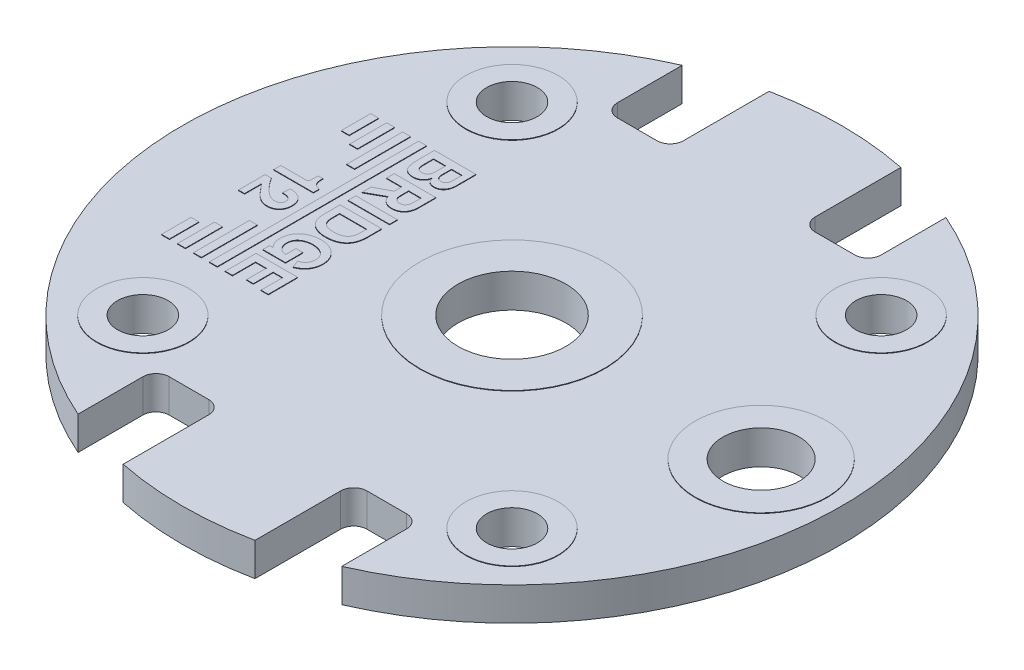
from build123d import *

# Parameters (mm, degrees)
BOSS_EXTRUDE1_DEPTH   = 0.8
SKETCH12_R            = 2.6
CUT_EXTRUDE2_DEPTH    = 23.507582056
F_2_CLEARANCE_HOLE1_D = 2.4384
SKETCH6_R             = 1.8415
CUT_EXTRUDE1_DEPTH    = 23.507582056
SKETCH8_R             = 2.2225
SKETCH8_R_2           = 1.2192
SKETCH8_R_3           = 3.175
SKETCH8_R_4           = 1.8415
SKETCH8_R_5           = 4.445
SKETCH8_R_6           = 2.6
BOSS_EXTRUDE6_DEPTH   = 0.0254
SKETCH10_W            = 2.000200165
SKETCH10_H            = 0.376434594
SKETCH10_W_2          = 0.384040879
SKETCH10_H_2          = 2.6975922
SKETCH10_W_3          = 0.384179562
SKETCH10_H_3          = 1.785047947
SKETCH10_W_4          = 0.384111999
SKETCH10_H_4          = 1.42007434
SKETCH10_H_5          = 2.69760998
SKETCH10_H_6          = 1.785033723
SKETCH10_H_7          = 1.420021
SKETCH10_W_5          = 0.384040878
SKETCH10_H_8          = 10.078361606
BOSS_EXTRUDE7_DEPTH   = 0.0254


with BuildPart() as part:
    # Sketch1 → Boss-Extrude1 (new, symmetric)
    with BuildSketch(Plane(origin=(0, 0, 0), x_dir=(1, 0, 0), z_dir=(0, 1, 0))):
        with BuildLine():
            Line((-6.35, 14.549677831), (-6.35, 11.43))
            ThreePointArc((-6.35, 11.43), (-6.164012806, 10.980987194), (-5.715, 10.795))
            Line((-5.715, 10.795), (-3.81, 10.795))
            ThreePointArc((-3.81, 10.795), (-3.360987194, 10.980987194), (-3.175, 11.43))
            Line((-3.175, 11.43), (-3.175, 15.554259867))
            ThreePointArc((-3.175, 15.554259867), (0, 15.875), (3.175, 15.554259867))
            Line((3.175, 15.554259867), (3.175, 11.43))
            ThreePointArc((3.175, 11.43), (3.360987194, 10.980987194), (3.81, 10.795))
            Line((3.81, 10.795), (5.715, 10.795))
            ThreePointArc((5.715, 10.795), (6.164012806, 10.980987194), (6.35, 11.43))
            Line((6.35, 11.43), (6.35, 14.549677831))
            ThreePointArc((6.35, 14.549677831), (15.875, 0), (6.35, -14.549677831))
            Line((6.35, -14.549677831), (6.35, -11.43))
            ThreePointArc((6.35, -11.43), (6.164012806, -10.980987194), (5.715, -10.795))
            Line((5.715, -10.795), (3.81, -10.795))
            ThreePointArc((3.81, -10.795), (3.360987194, -10.980987194), (3.175, -11.43))
            Line((3.175, -11.43), (3.175, -15.554259867))
            ThreePointArc((3.175, -15.554259867), (0, -15.875), (-3.175, -15.554259867))
            Line((-3.175, -15.554259867), (-3.175, -11.43))
            ThreePointArc((-3.175, -11.43), (-3.360987194, -10.980987194), (-3.81, -10.795))
            Line((-3.81, -10.795), (-5.715, -10.795))
            ThreePointArc((-5.715, -10.795), (-6.164012806, -10.980987194), (-6.35, -11.43))
            Line((-6.35, -11.43), (-6.35, -14.549677831))
            ThreePointArc((-6.35, -14.549677831), (-15.875, 0), (-6.35, 14.549677831))
        make_face()
    extrude(amount=BOSS_EXTRUDE1_DEPTH, both=True)

    # Sketch12 → Cut-Extrude2 (cut, through all)
    with BuildSketch(Plane(origin=(0, 0.8, 0), x_dir=(1, 0, 0), z_dir=(0, 1, 0))):
        with Locations(Location((0, 0, 0), (0, 0, 270))):
            Circle(SKETCH12_R)
    extrude(amount=-CUT_EXTRUDE2_DEPTH, mode=Mode.SUBTRACT)

    # #2 Clearance Hole1 (through all)
    with Locations(Plane(origin=(0, 0.8, 0), x_dir=(1, 0, 0), z_dir=(0, 1, 0))):
        with Locations((-8.89, 8.89), (8.89, -8.89), (-8.89, -8.89), (8.89, 8.89)):
            Hole(F_2_CLEARANCE_HOLE1_D / 2)

    # Sketch6 → Cut-Extrude1 (cut, through all)
    with BuildSketch(Plane(origin=(0, 0.8, 0), x_dir=(1, 0, 0), z_dir=(0, 1, 0))):
        with Locations(Location((12, 0, 0), (0, 0, 270))):
            Circle(SKETCH6_R)
    extrude(amount=-CUT_EXTRUDE1_DEPTH, mode=Mode.SUBTRACT)

    # Sketch8 → Boss-Extrude6 (add)
    with BuildSketch(Plane(origin=(0, 0.8, 0), x_dir=(1, 0, 0), z_dir=(0, 1, 0))):
        with Locations(Location((-8.89, 8.89, 0), (0, 0, 270))):
            Circle(SKETCH8_R)
        with Locations(Location((-8.89, 8.89, 0), (0, 0, 270))):
            Circle(SKETCH8_R_2, mode=Mode.SUBTRACT)
        with Locations(Location((8.89, 8.89, 0), (0, 0, 270))):
            Circle(SKETCH8_R)
        with Locations(Location((8.89, 8.89, 0), (0, 0, 270))):
            Circle(SKETCH8_R_2, mode=Mode.SUBTRACT)
        with Locations(Location((12, 0, 0), (0, 0, 270))):
            Circle(SKETCH8_R_3)
        with Locations(Location((12, 0, 0), (0, 0, 270))):
            Circle(SKETCH8_R_4, mode=Mode.SUBTRACT)
        with Locations(Location((0, 0, 0), (0, 0, 270))):
            Circle(SKETCH8_R_5)
        with Locations(Location((0, 0, 0), (0, 0, 270))):
            Circle(SKETCH8_R_6, mode=Mode.SUBTRACT)
        with Locations(Location((8.89, -8.89, 0), (0, 0, 270))):
            Circle(SKETCH8_R)
        with Locations(Location((8.89, -8.89, 0), (0, 0, 270))):
            Circle(SKETCH8_R_2, mode=Mode.SUBTRACT)
        with Locations(Location((-8.89, -8.89, 0), (0, 0, 270))):
            Circle(SKETCH8_R)
        with Locations(Location((-8.89, -8.89, 0), (0, 0, 270))):
            Circle(SKETCH8_R_2, mode=Mode.SUBTRACT)
    extrude(amount=BOSS_EXTRUDE6_DEPTH)

    # Sketch10 → Boss-Extrude7 (add)
    with BuildSketch(Plane(origin=(0, 0.8, 0), x_dir=(1, 0, 0), z_dir=(0, 1, 0))):
        with BuildLine():
            Line((-6.741945628, 5.008278357), (-6.741945628, 4.067190093))
            add(Edge.make_bspline(
                [(-6.741945628, 4.067190093), (-6.741945628, 3.738501909), (-6.907697896, 3.474444024), (-7.239195319, 3.474444024)],
                knots=[1, 1, 1, 1, 2, 2, 2, 2], degree=3))
            add(Edge.make_bspline(
                [(-7.239195319, 3.474444024), (-7.458323146, 3.474444024), (-7.60158727, 3.595237784), (-7.643725869, 3.814344275)],
                knots=[2, 2, 2, 2, 3, 3, 3, 3], degree=3))
            Line((-7.643725869, 3.814344275), (-7.649351461, 3.814344275))
            add(Edge.make_bspline(
                [(-7.649351461, 3.814344275), (-7.677429636, 3.53904943), (-7.904992294, 3.384534122), (-8.143770576, 3.384534122)],
                knots=[4, 4, 4, 4, 5, 5, 5, 5], degree=3))
            add(Edge.make_bspline(
                [(-8.143770576, 3.384534122), (-8.643833064, 3.384534122), (-8.742145793, 3.741314705), (-8.742145793, 4.157078658)],
                knots=[5, 5, 5, 5, 6, 6, 6, 6], degree=3))
            Line((-8.742145793, 4.157078658), (-8.742145793, 5.008278357))
            Line((-8.742145793, 5.008278357), (-6.741945628, 5.008278357))
        make_face()
        with BuildLine():
            Line((-8.410644814, 4.631843762), (-8.410644814, 4.143032459))
            add(Edge.make_bspline(
                [(-8.410644814, 4.143032459), (-8.410644814, 3.91548758), (-8.340428039, 3.777831268), (-8.132536816, 3.777831268)],
                knots=[1, 1, 1, 1, 2, 2, 2, 2], degree=3))
            add(Edge.make_bspline(
                [(-8.132536816, 3.777831268), (-7.90778731, 3.777831268), (-7.826319352, 3.918300376), (-7.826319352, 4.145845255)],
                knots=[2, 2, 2, 2, 3, 3, 3, 3], degree=3))
            Line((-7.826319352, 4.145845255), (-7.826319352, 4.631843762))
            Line((-7.826319352, 4.631843762), (-8.410644814, 4.631843762))
        make_face(mode=Mode.SUBTRACT)
        with BuildLine():
            Line((-7.545398916, 4.631843762), (-7.545398916, 4.185174614))
            add(Edge.make_bspline(
                [(-7.545398916, 4.185174614), (-7.545398916, 4.019422346), (-7.480789953, 3.867737614), (-7.289758082, 3.867737614)],
                knots=[1, 1, 1, 1, 2, 2, 2, 2], degree=3))
            add(Edge.make_bspline(
                [(-7.289758082, 3.867737614), (-7.13805557, 3.867737614), (-7.039728616, 3.966050343), (-7.039728616, 4.185174614)],
                knots=[2, 2, 2, 2, 3, 3, 3, 3], degree=3))
            Line((-7.039728616, 4.185174614), (-7.039728616, 4.631843762))
            Line((-7.039728616, 4.631843762), (-7.545398916, 4.631843762))
        make_face(mode=Mode.SUBTRACT)
        with BuildLine():
            Line((-6.741945628, 3.07274405), (-6.741945628, 2.238403347))
            add(Edge.make_bspline(
                [(-6.741945628, 2.238403347), (-6.741945628, 1.814201005), (-6.994791445, 1.564185764), (-7.345946437, 1.564185764)],
                knots=[1, 1, 1, 1, 2, 2, 2, 2], degree=3))
            add(Edge.make_bspline(
                [(-7.345946437, 1.564185764), (-7.795428016, 1.564185764), (-7.899366703, 1.864760212), (-7.93587971, 1.960277926)],
                knots=[2, 2, 2, 2, 3, 3, 3, 3], degree=3))
            Line((-7.93587971, 1.960277926), (-8.742145793, 1.513605221))
            Line((-8.742145793, 1.513605221), (-8.742145793, 1.949044522))
            Line((-8.742145793, 1.949044522), (-8.006114264, 2.3367303))
            Line((-8.006114264, 2.3367303), (-8.006114264, 2.696305899))
            Line((-8.006114264, 2.696305899), (-8.742145793, 2.696305899))
            Line((-8.742145793, 2.696305899), (-8.742145793, 3.07274405))
            Line((-8.742145793, 3.07274405), (-6.741945628, 3.07274405))
        make_face()
        with BuildLine():
            Line((-7.67463462, 2.696305899), (-7.67463462, 2.286149758))
            add(Edge.make_bspline(
                [(-7.67463462, 2.286149758), (-7.67463462, 2.095139222), (-7.562257911, 1.95748291), (-7.374038836, 1.95748291)],
                knots=[1, 1, 1, 1, 2, 2, 2, 2], degree=3))
            add(Edge.make_bspline(
                [(-7.374038836, 1.95748291), (-7.191431129, 1.95748291), (-7.073446607, 2.081089467), (-7.073446607, 2.342338112)],
                knots=[2, 2, 2, 2, 3, 3, 3, 3], degree=3))
            Line((-7.073446607, 2.342338112), (-7.073446607, 2.696305899))
            Line((-7.073446607, 2.696305899), (-7.67463462, 2.696305899))
        make_face(mode=Mode.SUBTRACT)
        with Locations((-7.742045711, 1.033269643)):
            Rectangle(SKETCH10_W, SKETCH10_H)
        with BuildLine():
            Line((-6.741945628, 0.46578362), (-6.741945628, -0.236508583))
            add(Edge.make_bspline(
                [(-6.741945628, -0.236508583), (-6.741945628, -0.927599385), (-7.168960765, -1.219757094), (-7.742056379, -1.219757094)],
                knots=[1, 1, 1, 1, 2, 2, 2, 2], degree=3))
            add(Edge.make_bspline(
                [(-7.742056379, -1.219757094), (-8.393803598, -1.219757094), (-8.742145793, -0.902319782), (-8.742145793, -0.306760917)],
                knots=[2, 2, 2, 2, 3, 3, 3, 3], degree=3))
            Line((-8.742145793, -0.306760917), (-8.742145793, 0.46578362))
            Line((-8.742145793, 0.46578362), (-6.741945628, 0.46578362))
        make_face()
        with BuildLine():
            Line((-8.393803598, 0.089366805), (-8.393803598, -0.253385358))
            add(Edge.make_bspline(
                [(-8.393803598, -0.253385358), (-8.393803598, -0.624194361), (-8.258960082, -0.826477416), (-7.742056379, -0.826477416)],
                knots=[1, 1, 1, 1, 2, 2, 2, 2], degree=3))
            add(Edge.make_bspline(
                [(-7.742056379, -0.826477416), (-7.348758856, -0.826477416), (-7.090305603, -0.655103112), (-7.090305603, -0.244946971)],
                knots=[2, 2, 2, 2, 3, 3, 3, 3], degree=3))
            Line((-7.090305603, -0.244946971), (-7.090305603, 0.089366805))
            Line((-7.090305603, 0.089366805), (-8.393803598, 0.089366805))
        make_face(mode=Mode.SUBTRACT)
        with BuildLine():
            Line((-7.980834661, -2.917465815), (-7.980834661, -2.423032475))
            Line((-7.980834661, -2.423032475), (-7.649351461, -2.423032475))
            Line((-7.649351461, -2.423032475), (-7.649351461, -3.260182418))
            Line((-7.649351461, -3.260182418), (-8.742145793, -3.260182418))
            Line((-8.742145793, -3.260182418), (-8.742145793, -2.934310587))
            Line((-8.742145793, -2.934310587), (-8.570767934, -2.934310587))
            add(Edge.make_bspline(
                [(-8.570767934, -2.934310587), (-8.71967543, -2.802279866), (-8.792708216, -2.583155595), (-8.792708216, -2.4090005)],
                knots=[10, 10, 10, 10, 11, 11, 11, 11], degree=3))
            add(Edge.make_bspline(
                [(-8.792708216, -2.4090005), (-8.792708216, -1.768468904), (-8.306709696, -1.45103546), (-7.742056379, -1.45103546)],
                knots=[11, 11, 11, 11, 12, 12, 12, 12], degree=3))
            add(Edge.make_bspline(
                [(-7.742056379, -1.45103546), (-7.177384929, -1.45103546), (-6.691386421, -1.810628839), (-6.691386421, -2.4090005)],
                knots=[12, 12, 12, 12, 13, 13, 13, 13], degree=3))
            add(Edge.make_bspline(
                [(-6.691386421, -2.4090005), (-6.691386421, -2.816343846), (-6.896464492, -3.108497686), (-7.278524678, -3.260182418)],
                knots=[13, 13, 13, 13, 14, 14, 14, 14], degree=3))
            Line((-7.278524678, -3.260182418), (-7.421788803, -2.909027427))
            add(Edge.make_bspline(
                [(-7.421788803, -2.909027427), (-7.261665683, -2.866906608), (-7.039728616, -2.740465919), (-7.039728616, -2.4090005)],
                knots=[0, 0, 0, 0, 1, 1, 1, 1], degree=3))
            add(Edge.make_bspline(
                [(-7.039728616, -2.4090005), (-7.039728616, -2.010063538), (-7.393696403, -1.84431127), (-7.742056379, -1.84431127)],
                knots=[1, 1, 1, 1, 2, 2, 2, 2], degree=3))
            add(Edge.make_bspline(
                [(-7.742056379, -1.84431127), (-8.090398216, -1.84431127), (-8.444366361, -2.010063538), (-8.444366361, -2.4090005)],
                knots=[2, 2, 2, 2, 3, 3, 3, 3], degree=3))
            add(Edge.make_bspline(
                [(-8.444366361, -2.4090005), (-8.444366361, -2.675874737), (-8.256147286, -2.917465815), (-7.980834661, -2.917465815)],
                knots=[3, 3, 3, 3, 4, 4, 4, 4], degree=3))
        make_face()
        Polygon((-6.741945628, -3.580674022), (-6.741945628, -4.99654517), (-7.090305603, -4.99654517), (-7.090305603, -3.957112173), (-7.545398916, -3.957112173), (-7.545398916, -4.912264417), (-7.876895976, -4.912264417), (-7.876895976, -3.957112173), (-8.393803598, -3.957112173), (-8.393803598, -5.069578297), (-8.742145793, -5.069578297), (-8.742145793, -3.580674022), align=None)
        with BuildLine():
            Line((-10.482917985, 0.838697774), (-10.482917985, 1.142085018))
            Line((-10.482917985, 1.142085018), (-10.252542531, 1.142085018))
            Line((-10.252542531, 1.142085018), (-10.252542531, 1.085896664))
            add(Edge.make_bspline(
                [(-10.252542531, 1.085896664), (-10.252542531, 0.745975076), (-10.112108983, 0.664507119), (-9.90138754, 0.616757152)],
                knots=[4, 4, 4, 4, 5, 5, 5, 5], degree=3))
            Line((-9.90138754, 0.616757152), (-9.90138754, 0.335836715))
            Line((-9.90138754, 0.335836715), (-11.811695584, 0.335836715))
            Line((-11.811695584, 0.335836715), (-11.811695584, 0.678553318))
            Line((-11.811695584, 0.678553318), (-10.671137061, 0.678553318))
            add(Edge.make_bspline(
                [(-10.671137061, 0.678553318), (-10.519448772, 0.678553318), (-10.482917985, 0.706649273), (-10.482917985, 0.838697774)],
                knots=[0, 0, 0, 0, 1, 1, 1, 1], degree=3))
        make_face()
        with BuildLine():
            Line((-11.513916151, -0.540642587), (-11.513916151, -1.366544902))
            Line((-11.513916151, -1.366544902), (-11.811695584, -1.366544902))
            Line((-11.811695584, -1.366544902), (-11.811695584, -0.074298374))
            Line((-11.811695584, -0.074298374), (-11.513916151, -0.074298374))
            add(Edge.make_bspline(
                [(-11.513916151, -0.074298374), (-11.348163883, -0.349610716), (-10.895886923, -0.945173137), (-10.491356373, -0.945173137)],
                knots=[7, 7, 7, 7, 8, 8, 8, 8], degree=3))
            add(Edge.make_bspline(
                [(-10.491356373, -0.945173137), (-10.339636081, -0.945173137), (-10.199166973, -0.894610374), (-10.199166973, -0.689514523)],
                knots=[8, 8, 8, 8, 9, 9, 9, 9], degree=3))
            add(Edge.make_bspline(
                [(-10.199166973, -0.689514523), (-10.199166973, -0.481641437), (-10.370540976, -0.417014694), (-10.631789922, -0.417014694)],
                knots=[9, 9, 9, 9, 10, 10, 10, 10], degree=3))
            Line((-10.631789922, -0.417014694), (-10.606510318, -0.074298374))
            add(Edge.make_bspline(
                [(-10.606510318, -0.074298374), (-10.171074573, -0.074298374), (-9.867701553, -0.268142758), (-9.867701553, -0.731674458)],
                knots=[0, 0, 0, 0, 1, 1, 1, 1], degree=3))
            add(Edge.make_bspline(
                [(-9.867701553, -0.731674458), (-9.867701553, -1.094045073), (-10.098044696, -1.338452503), (-10.460451178, -1.338452503)],
                knots=[1, 1, 1, 1, 2, 2, 2, 2], degree=3))
            add(Edge.make_bspline(
                [(-10.460451178, -1.338452503), (-10.963290616, -1.338452503), (-11.227384347, -0.880546394), (-11.513916151, -0.540642587)],
                knots=[2, 2, 2, 2, 3, 3, 3, 3], degree=3))
        make_face()
        with Locations((-10.085766136, -3.719217557)):
            Rectangle(SKETCH10_W_2, SKETCH10_H_2)
        with Locations((-10.854023914, -4.175489684)):
            Rectangle(SKETCH10_W_3, SKETCH10_H_3)
        with Locations((-11.622313697, -4.357976487)):
            Rectangle(SKETCH10_W_4, SKETCH10_H_4)
        with Locations((-10.085766136, 3.661610523)):
            Rectangle(SKETCH10_W_2, SKETCH10_H_5)
        with Locations((-10.854023914, 4.117898652)):
            Rectangle(SKETCH10_W_3, SKETCH10_H_6)
        with Locations((-11.622313697, 4.300405013)):
            Rectangle(SKETCH10_W_4, SKETCH10_H_7)
        with Locations((-9.317478131, -0.02876529)):
            Rectangle(SKETCH10_W_5, SKETCH10_H_8)
    extrude(amount=BOSS_EXTRUDE7_DEPTH)


solid = part.part
